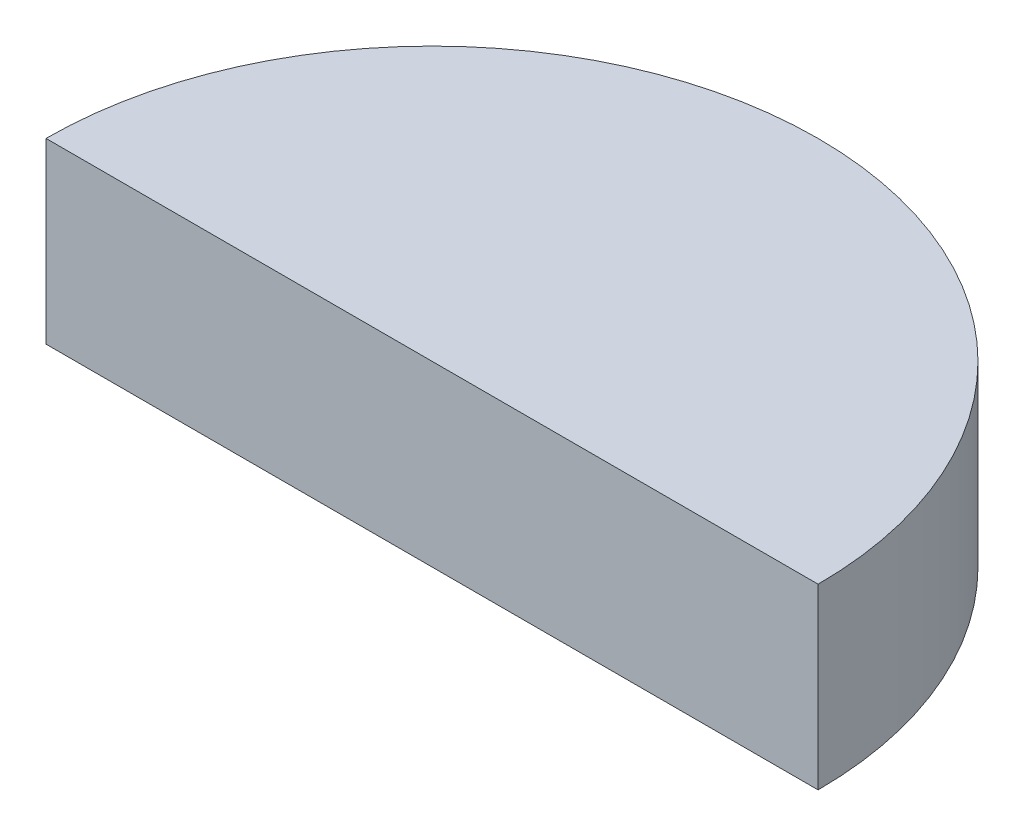
from build123d import *

# Parameters (mm, degrees)
BOSS_EXTRUDE1_DEPTH = 6


with BuildPart() as part:
    # Sketch2 → Boss-Extrude1 (new body)
    with BuildSketch(Plane(origin=(0, 0, 0), x_dir=(1, 0, 0), z_dir=(0, 1, 0))):
        with BuildLine():
            Line((-13, 0), (13, 0))
            ThreePointArc((13, 0), (0, 13), (-13, 0))
        make_face()
    extrude(amount=BOSS_EXTRUDE1_DEPTH)


solid = part.part
